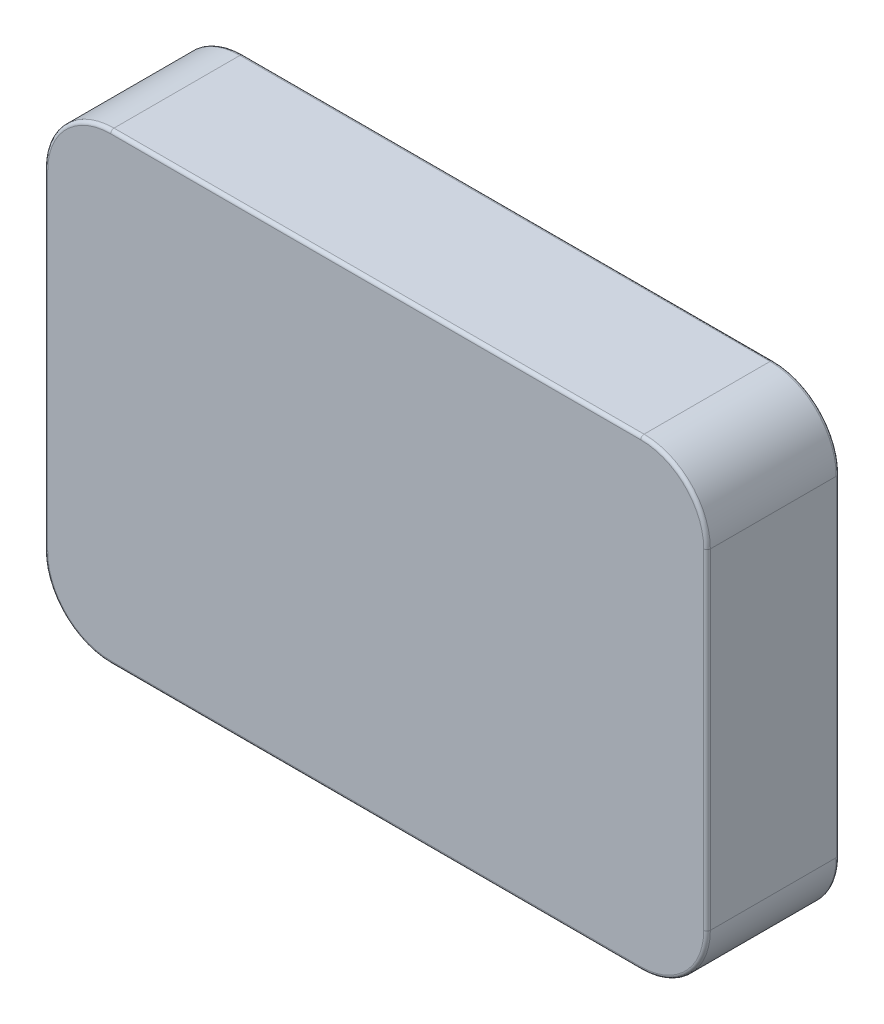
from build123d import *

# Parameters (mm, degrees)
SKETCH1_W           = 100
SKETCH1_H           = 69.85
BOSS_EXTRUDE1_DEPTH = 20
FILLET1_R           = 10
FILLET2_R           = 0.5


with BuildPart() as part:
    # Sketch1 → Boss-Extrude1 (new body)
    with BuildSketch(Plane.XY):
        Rectangle(SKETCH1_W, SKETCH1_H)
    extrude(amount=BOSS_EXTRUDE1_DEPTH)

    # Fillet1
    fillet1_edges = [part.edges().sort_by_distance(p)[0] for p in [
        (50, -34.925, 10),
        (-50, -34.925, 10),
        (-50, 34.925, 10),
        (50, 34.925, 10),
    ]]
    fillet(fillet1_edges, radius=FILLET1_R)

    # Fillet2
    fillet2_edges = [part.edges().sort_by_distance(p)[0] for p in [
        (0, -34.925, 0),
        (0, -34.925, 20),
        (50, 0, 0),
        (-50, 0, 0),
        (0, 34.925, 0),
        (-47.071067812, 31.996067812, 0),
        (47.071067812, 31.996067812, 0),
        (47.071067812, -31.996067812, 0),
        (-47.071067812, -31.996067812, 0),
        (-50, 0, 20),
        (50, 0, 20),
        (0, 34.925, 20),
        (-47.071067812, 31.996067812, 20),
        (47.071067812, 31.996067812, 20),
        (47.071067812, -31.996067812, 20),
        (-47.071067812, -31.996067812, 20),
    ]]
    fillet(fillet2_edges, radius=FILLET2_R)


solid = part.part
